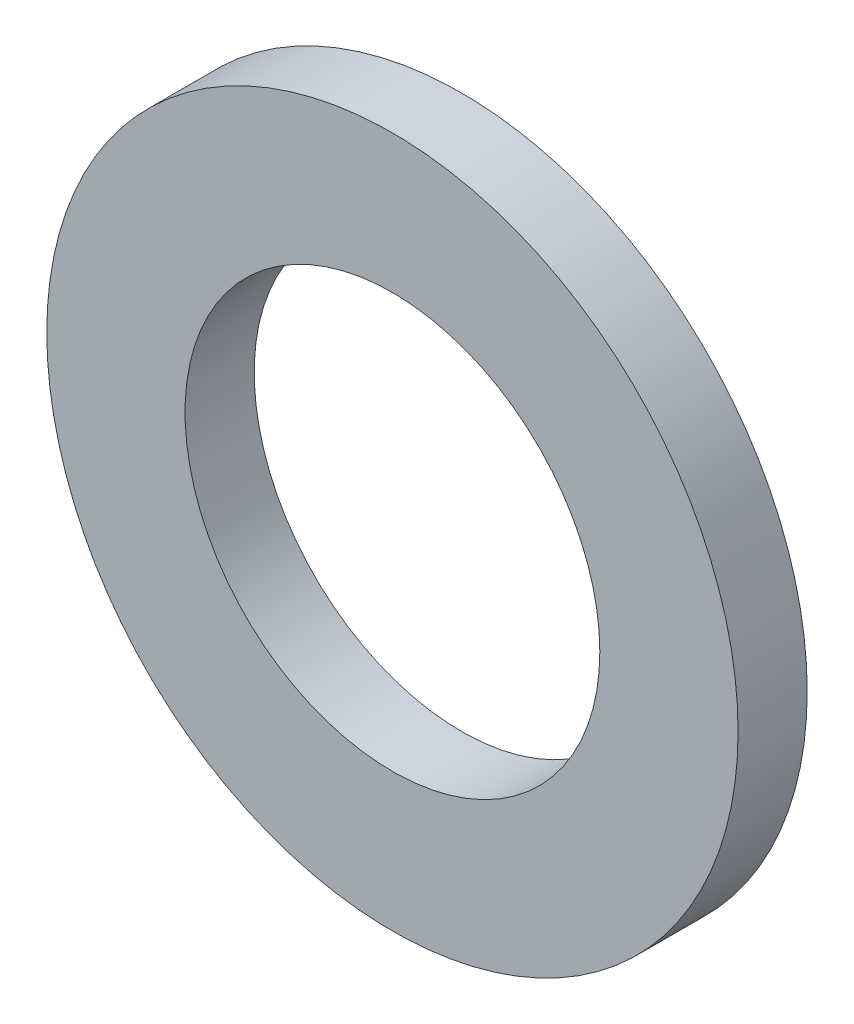
from build123d import *

# Parameters (mm, degrees)
ESQUISSE1_R        = 5
ESQUISSE1_R_2      = 3
BOSS_EXTRU_1_DEPTH = 1


with BuildPart() as part:
    # Esquisse1 → Boss.-Extru.1 (new body)
    with BuildSketch(Plane.XY):
        Circle(ESQUISSE1_R)
        Circle(ESQUISSE1_R_2, mode=Mode.SUBTRACT)
    extrude(amount=BOSS_EXTRU_1_DEPTH)


solid = part.part
